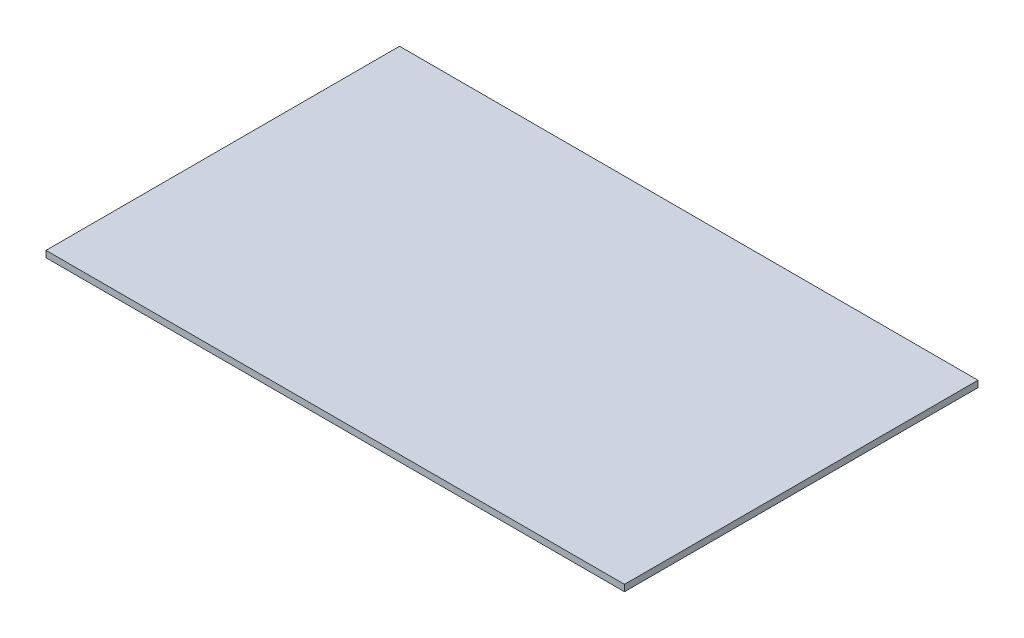
from build123d import *

# Parameters (mm, degrees)
SKETCH1_W           = 90
SKETCH1_H           = 55
BOSS_EXTRUDE1_DEPTH = 1


with BuildPart() as part:
    # Sketch1 → Boss-Extrude1 (new body)
    with BuildSketch(Plane(origin=(0, 0, 0), x_dir=(1, 0, 0), z_dir=(0, 1, 0))):
        with Locations((45, 27.5)):
            Rectangle(SKETCH1_W, SKETCH1_H)
    extrude(amount=BOSS_EXTRUDE1_DEPTH)


solid = part.part
